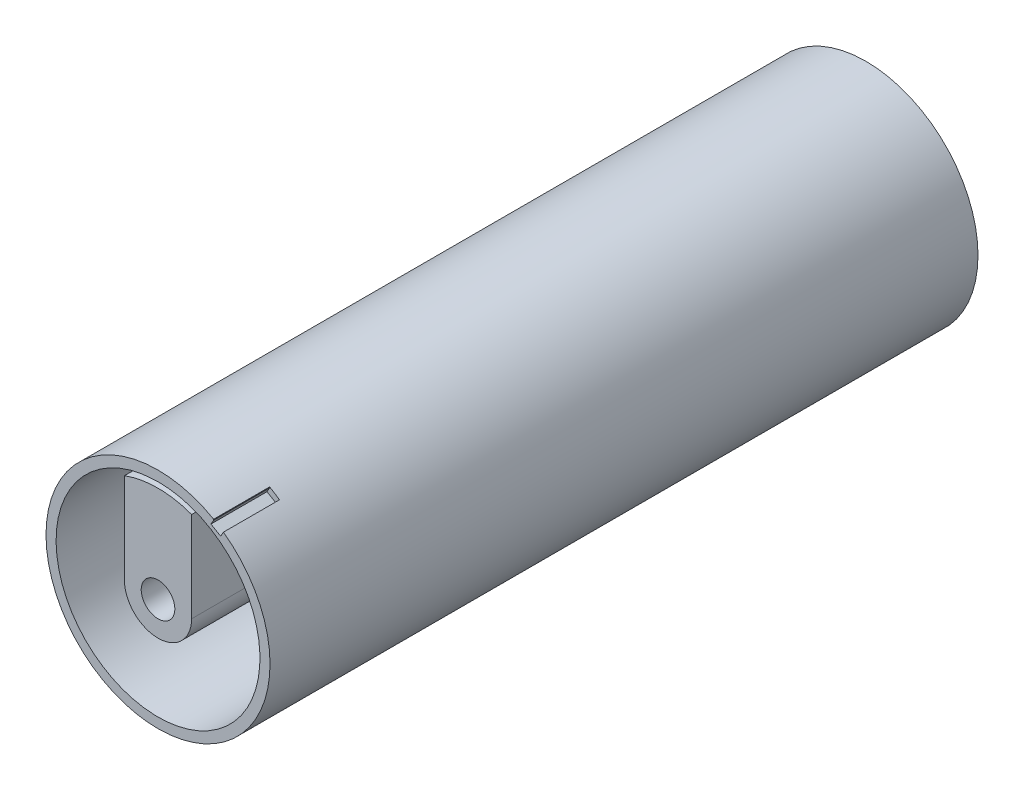
from build123d import *

# Parameters (mm, degrees)
SKETCH_2_R          = 20
SKETCH_2_R_2        = 18.2
EXTRUDE_1_DEPTH     = 126.4
SKETCH_5_R          = 3
EXTRUDE_3_DEPTH     = 126.4
CUT_EXTRUDE1_DEPTH  = 59
CUT_EXTRUDE2_DEPTH  = 59
SKETCH3_R           = 3
BOSS_EXTRUDE1_DEPTH = 58.6
CUT_EXTRUDE3_DEPTH  = 10


with BuildPart() as part:
    # Эскиз2 → Бобышка-Вытянуть1 (new body)
    with BuildSketch(Plane.XY):
        Circle(SKETCH_2_R)
        Circle(SKETCH_2_R_2, mode=Mode.SUBTRACT)
    extrude(amount=EXTRUDE_1_DEPTH)

    # Эскиз5 → Бобышка-Вытянуть3 (add, through all)
    with BuildSketch(Plane(origin=(0, 0, 0), x_dir=(-1, 0, 0), z_dir=(0, 0, -1))):
        with BuildLine():
            Line((0, 18.2), (0, 9.219544457))
            ThreePointArc((0, 9.219544457), (-0.725705562, 6.35915669), (-2.727272727, 4.190702026))
            ThreePointArc((-2.727272727, 4.190702026), (-0.412087912, -4.982989419), (3.378646828, 3.685748989))
            ThreePointArc((3.378646828, 3.685748989), (1.760493123, 6.153550709), (1.514534917, 9.094294034))
            Line((1.514534917, 9.094294034), (2.989793652, 17.952747253))
            ThreePointArc((2.989793652, 17.952747253), (1.5, 18.138081486), (0, 18.2))
        make_face()
        Circle(SKETCH_5_R, mode=Mode.SUBTRACT)
    extrude(amount=-EXTRUDE_3_DEPTH)

    # Sketch1 → Cut-Extrude1 (cut)
    with BuildSketch(Plane(origin=(0, 0, 0), x_dir=(-1, 0, 0), z_dir=(0, 0, -1))):
        with BuildLine():
            Line((0, 18.2), (2.989793652, 17.952747253))
            ThreePointArc((2.989793652, 17.952747253), (-1.5, -18.138081486), (0, 18.2))
        make_face()
    extrude(amount=-CUT_EXTRUDE1_DEPTH, mode=Mode.SUBTRACT)

    # Sketch2 → Cut-Extrude2 (cut)
    with BuildSketch(Plane.XY.offset(126.4)):
        with BuildLine():
            Line((0, 18.2), (-2.989793652, 17.952747253))
            ThreePointArc((-2.989793652, 17.952747253), (1.5, -18.138081486), (0, 18.2))
        make_face()
    extrude(amount=-CUT_EXTRUDE2_DEPTH, mode=Mode.SUBTRACT)

    # Sketch4 → Cut-Extrude3 (cut)
    with BuildSketch(Plane.XY.offset(126.4)):
        with BuildLine():
            Line((9.949874371, 17.23368794), (9.449874371, 16.367662536))
            Line((9.449874371, 16.367662536), (11.181925179, 15.367662536))
            Line((11.181925179, 15.367662536), (11.681925179, 16.23368794))
            ThreePointArc((11.681925179, 16.23368794), (11.905777201, 18.621411015), (9.949874371, 17.23368794))
        make_face()
    extrude(amount=-CUT_EXTRUDE3_DEPTH, mode=Mode.SUBTRACT)


with BuildPart() as body_2:
    # Sketch3 → Boss-Extrude1 (new body)
    with BuildSketch(Plane.XY.offset(126.4)):
        with BuildLine():
            Line((6, 0), (6, 16.119553344))
            ThreePointArc((6, 16.119553344), (0, 17.2), (-6, 16.119553344))
            Line((-6, 16.119553344), (-6, 0))
            ThreePointArc((-6, 0), (0, -6), (6, 0))
        make_face()
        Circle(SKETCH3_R, mode=Mode.SUBTRACT)
    extrude(amount=-BOSS_EXTRUDE1_DEPTH)


solid = Compound([part.part, body_2.part])
